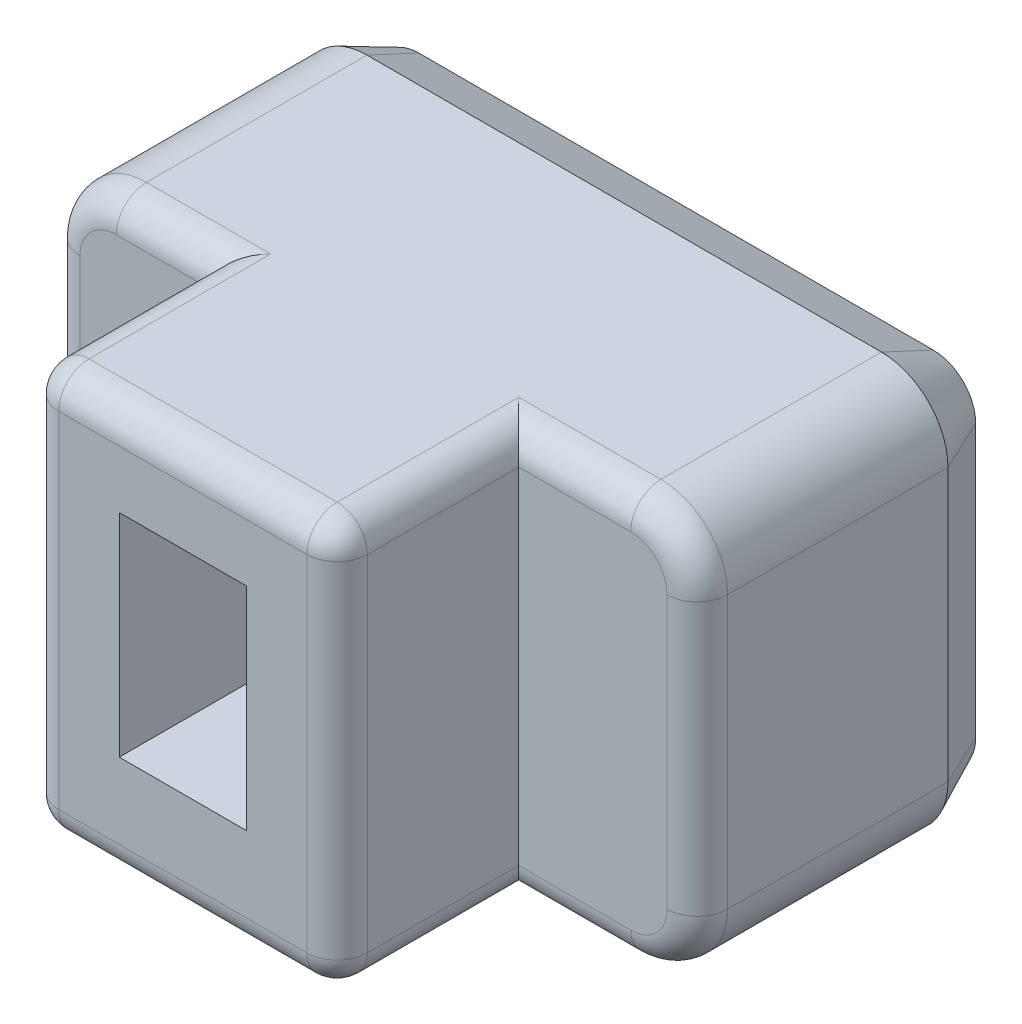
from build123d import *

# Parameters (mm, degrees)
BOSS_EXTRU_1_DEPTH      = 8
ESQUISSE3_W             = 2.1
ESQUISSE3_H             = 3.5
ENL_V_MAT_EXTRU_1_DEPTH = 3
ESQUISSE4_OUTSIDE_W     = 15.69
ESQUISSE4_OUTSIDE_H     = 11.69
ESQUISSE4_OUTSIDE_W_2   = 5.1
ESQUISSE4_OUTSIDE_H_2   = 6.7
ENL_V_MAT_EXTRU_2_DEPTH = 3
CONG_1_R                = 0.5
CHANFREIN1_SIZE         = 0.4
CHANFREIN1_SIZE2        = 0.857802768
ESQUISSE5_W             = 1.025354295
ESQUISSE5_H             = 0.378985829
ENL_V_MAT_EXTRU_3_DEPTH = 0.2
BOSS_EXTRU_2_DEPTH      = 0.2
ESQUISSE5_4_W           = 1.025354295
ESQUISSE5_4_H           = 0.378985829
BOSS_EXTRU_2_2_DEPTH    = 0.2
BOSS_EXTRU_2_3_DEPTH    = 0.2


with BuildPart() as part:
    # Esquisse2 → Boss.-Extru.1 (new body)
    with BuildSketch(Plane.XY):
        with BuildLine():
            Line((1.1, 0), (9.6, 0))
            ThreePointArc((9.6, 0), (10.377817459, 0.322182541), (10.7, 1.1))
            Line((10.7, 1.1), (10.7, 5.6))
            ThreePointArc((10.7, 5.6), (10.377817459, 6.377817459), (9.6, 6.7))
            Line((9.6, 6.7), (1.1, 6.7))
            ThreePointArc((1.1, 6.7), (0.322182541, 6.377817459), (0, 5.6))
            Line((0, 5.6), (0, 1.1))
            ThreePointArc((0, 1.1), (0.322182541, 0.322182541), (1.1, 0))
        make_face()
    extrude(amount=BOSS_EXTRU_1_DEPTH)

    # Esquisse3 → Enlèv. mat.-Extru.1 (cut)
    with BuildSketch(Plane.XY.offset(8)):
        with Locations((5.2, 3.5)):
            Rectangle(ESQUISSE3_W, ESQUISSE3_H)
    extrude(amount=-ENL_V_MAT_EXTRU_1_DEPTH, mode=Mode.SUBTRACT)

    # Esquisse4 outside → Enlèv. mat.-Extru.2 (cut)
    with BuildSketch(Plane.XY.offset(8)):
        with Locations((5.35, 3.35)):
            Rectangle(ESQUISSE4_OUTSIDE_W, ESQUISSE4_OUTSIDE_H)
        with Locations((5.2, 3.35)):
            Rectangle(ESQUISSE4_OUTSIDE_W_2, ESQUISSE4_OUTSIDE_H_2, mode=Mode.SUBTRACT)
    extrude(amount=-ENL_V_MAT_EXTRU_2_DEPTH, mode=Mode.SUBTRACT)

    # Congé1
    cong_1_edges = [part.edges().sort_by_distance(p)[0] for p in [
        (8.675, 0, 5),
        (10.377817459, 0.322182541, 5),
        (10.7, 3.35, 5),
        (10.377817459, 6.377817459, 5),
        (1.875, 6.7, 5),
        (0.322182541, 6.377817459, 5),
        (1.875, 0, 5),
        (0.322182541, 0.322182541, 5),
        (7.75, 6.7, 6.5),
        (2.65, 6.7, 6.5),
        (7.75, 0, 6.5),
        (2.65, 0, 6.5),
        (2.65, 3.35, 8),
        (5.2, 6.7, 8),
        (7.75, 3.35, 8),
        (5.2, 0, 8),
        (8.675, 6.7, 5),
        (0, 3.35, 5),
    ]]
    fillet(cong_1_edges, radius=CONG_1_R)

    # Chanfrein1
    chanfrein1_edges = [part.edges().sort_by_distance(p)[0] for p in [
        (5.35, 0, 0),
        (10.377817459, 0.322182541, 0),
        (0.322182541, 0.322182541, 0),
        (10.7, 3.35, 0),
        (0, 3.35, 0),
        (10.377817459, 6.377817459, 0),
        (0.322182541, 6.377817459, 0),
        (5.35, 6.7, 0),
    ]]
    chanfrein1_side = [part.faces().sort_by_distance(p)[0] for p in [
        (5.35, 3.35, 0),
    ]]
    chamfer(chanfrein1_edges, length=CHANFREIN1_SIZE, length2=CHANFREIN1_SIZE2, reference=chanfrein1_side[0])

    # Esquisse5 → Enlèv. mat.-Extru.3 (cut)
    # profile 1 of 3: a face of its own
    with BuildSketch(Plane.XY):
        with BuildLine():
            add(Edge.make_bspline(
                [(4.929449844, 3.327498458), (4.928886171, 3.377910145), (4.927777021, 3.477106133), (4.913601196, 3.623501248), (4.893366306, 3.765198874), (4.863662836, 3.902141775), (4.826132718, 4.033610013), (4.779556169, 4.158797974), (4.724522324, 4.277096054), (4.660463786, 4.388376577), (4.588776461, 4.493574952), (4.506874555, 4.590024638), (4.418032325, 4.680339759), (4.320049141, 4.762328436), (4.213891625, 4.837218253), (4.098307941, 4.90208427), (3.974955321, 4.959484949), (3.887876016, 4.988919822), (3.843643821, 5.003871354)],
                knots=[0, 0, 0, 0, 1.123878421, 2.21147591, 3.277260197, 4.314665604, 5.334010396, 6.323947346, 7.290538082, 8.24029135, 9.184804826, 10.125373713, 11.058341454, 12.007028084, 12.970867444, 13.951353182, 14.959383669, 16, 16, 16, 16], degree=3))
            add(Edge.make_bspline(
                [(3.843643821, 5.003871354), (3.789912082, 5.019016461), (3.679254836, 5.050206887), (3.502499471, 5.075001227), (3.312810463, 5.091003658), (3.181557586, 5.092318076), (3.113572962, 5.092998901)],
                knots=[0, 0, 0, 0, 0.90656597, 1.867017452, 2.895185995, 4, 4, 4, 4], degree=3))
            Line((3.113572962, 5.092998901), (2.409077833, 5.092998901))
            Line((2.409077833, 5.092998901), (2.409077833, 1.592998901))
            Line((2.409077833, 1.592998901), (3.120548161, 1.592998901))
            add(Edge.make_bspline(
                [(3.120548161, 1.592998901), (3.188520627, 1.593804974), (3.319729447, 1.595360956), (3.50960112, 1.609682498), (3.686149149, 1.636076993), (3.796873472, 1.667078383), (3.85061902, 1.682126447)],
                knots=[0, 0, 0, 0, 1.104726419, 2.132478913, 3.093505899, 4, 4, 4, 4], degree=3))
            add(Edge.make_bspline(
                [(3.85061902, 1.682126447), (3.894821605, 1.697142904), (3.981741078, 1.726671098), (4.105308916, 1.783032384), (4.220562381, 1.847357764), (4.326977684, 1.920222615), (4.42442678, 2.001555403), (4.513450744, 2.089645794), (4.59386311, 2.184840849), (4.665312975, 2.28683289), (4.72859397, 2.395515198), (4.781344797, 2.511870914), (4.82858433, 2.633347502), (4.865450647, 2.761858032), (4.893756086, 2.895844348), (4.914835009, 3.035029601), (4.927468569, 3.179490952), (4.928782066, 3.277613308), (4.929449844, 3.327498458)],
                knots=[0, 0, 0, 0, 1.055129885, 2.074795748, 3.0660858, 4.03671011, 4.986650223, 5.932630135, 6.865385513, 7.800552627, 8.745449603, 9.70470299, 10.686583926, 11.690463595, 12.723975734, 13.781512585, 14.872126769, 16, 16, 16, 16], degree=3))
        make_face()
        with BuildLine():
            add(Edge.make_bspline(
                [(4.529538418, 3.327498458), (4.528992862, 3.286400298), (4.527924312, 3.205903549), (4.518147111, 3.088501479), (4.504173153, 2.976755021), (4.481803596, 2.871363866), (4.455715845, 2.771170033), (4.420735035, 2.677813392), (4.381781679, 2.589786146), (4.335464015, 2.508236118), (4.284615762, 2.431743733), (4.226977419, 2.362134044), (4.164317439, 2.298073685), (4.097117361, 2.238916215), (4.024003907, 2.186300791), (3.945729841, 2.139362346), (3.862159311, 2.098319816), (3.803525417, 2.075663084), (3.773891828, 2.064212364)],
                knots=[0, 0, 0, 0, 1.246753459, 2.441948741, 3.572739138, 4.66116684, 5.708921826, 6.71080927, 7.682622944, 8.626727097, 9.552892984, 10.466231949, 11.364237833, 12.269773083, 13.17920167, 14.093347591, 15.036377251, 16, 16, 16, 16], degree=3))
            add(Edge.make_bspline(
                [(3.773891828, 2.064212364), (3.724847084, 2.049050908), (3.622993128, 2.017564266), (3.487675217, 1.99731781), (3.371721375, 1.988032345), (3.277452151, 1.981191627), (3.177653465, 1.978718026), (3.109181032, 1.97785349), (3.074046833, 1.977409884)],
                knots=[0, 0, 0, 0, 1.303000307, 2.706013413, 3.463799367, 4.259858732, 5.107108259, 6, 6, 6, 6], degree=3))
            Line((3.074046833, 1.977409884), (2.788063662, 1.977409884))
            Line((2.788063662, 1.977409884), (2.788063662, 4.708587918))
            Line((2.788063662, 4.708587918), (3.074046833, 4.708587918))
            add(Edge.make_bspline(
                [(3.074046833, 4.708587918), (3.109187702, 4.708605057), (3.177684847, 4.708638464), (3.277389955, 4.704111547), (3.371810318, 4.699378216), (3.487522058, 4.687803984), (3.623219634, 4.669854997), (3.72488446, 4.637420457), (3.773891828, 4.621785438)],
                knots=[0, 0, 0, 0, 0.892652841, 1.739973182, 2.535478049, 3.293719468, 4.695441758, 6, 6, 6, 6], degree=3))
            add(Edge.make_bspline(
                [(3.773891828, 4.621785438), (3.803541153, 4.61037347), (3.862313241, 4.587752207), (3.94599411, 4.545963014), (4.023785024, 4.497226527), (4.097351616, 4.443975775), (4.164848643, 4.383183707), (4.226696609, 4.316028425), (4.284926846, 4.24405854), (4.335439254, 4.164490225), (4.381795522, 4.079879262), (4.420758199, 3.988771473), (4.45542782, 3.892746892), (4.481946017, 3.790375103), (4.504148468, 3.682869359), (4.51805281, 3.569325495), (4.527958703, 3.450385665), (4.529003454, 3.369113736), (4.529538418, 3.327498458)],
                knots=[0, 0, 0, 0, 0.947957508, 1.879079663, 2.786395923, 3.685581737, 4.586617323, 5.49235929, 6.408837464, 7.345689656, 8.301456099, 9.285667611, 10.300283175, 11.345897504, 12.439299688, 13.574643735, 14.758096734, 16, 16, 16, 16], degree=3))
        make_face(mode=Mode.SUBTRACT)
    # profile 2 of 3: a face of its own
    with BuildSketch(Plane.XY):
        with Locations((5.751825841, 3.789024144)):
            Rectangle(ESQUISSE5_W, ESQUISSE5_H)
    # profile 3 of 3: a face of its own
    with BuildSketch(Plane.XY):
        Polygon((8.076194751, 3.709584375), (8.076194751, 3.698734065), (6.537000774, 2.851634862), (6.537000774, 2.458698635), (8.443555247, 3.525904127), (8.443555247, 3.881639291), (6.537000774, 4.948844782), (6.537000774, 4.556683578), align=None)
    extrude(amount=ENL_V_MAT_EXTRU_3_DEPTH, mode=Mode.SUBTRACT)


with BuildPart() as body_2:
    # Esquisse5_4 → Boss.-Extru.2 (new body)
    with BuildSketch(Plane.XY):
        with BuildLine():
            add(Edge.make_bspline(
                [(4.929449844, 3.327498458), (4.928886171, 3.377910145), (4.927777021, 3.477106133), (4.913601196, 3.623501248), (4.893366306, 3.765198874), (4.863662836, 3.902141775), (4.826132718, 4.033610013), (4.779556169, 4.158797974), (4.724522324, 4.277096054), (4.660463786, 4.388376577), (4.588776461, 4.493574952), (4.506874555, 4.590024638), (4.418032325, 4.680339759), (4.320049141, 4.762328436), (4.213891625, 4.837218253), (4.098307941, 4.90208427), (3.974955321, 4.959484949), (3.887876016, 4.988919822), (3.843643821, 5.003871354)],
                knots=[0, 0, 0, 0, 1.123878421, 2.21147591, 3.277260197, 4.314665604, 5.334010396, 6.323947346, 7.290538082, 8.24029135, 9.184804826, 10.125373713, 11.058341454, 12.007028084, 12.970867444, 13.951353182, 14.959383669, 16, 16, 16, 16], degree=3))
            add(Edge.make_bspline(
                [(3.843643821, 5.003871354), (3.789912082, 5.019016461), (3.679254836, 5.050206887), (3.502499471, 5.075001227), (3.312810463, 5.091003658), (3.181557586, 5.092318076), (3.113572962, 5.092998901)],
                knots=[0, 0, 0, 0, 0.90656597, 1.867017452, 2.895185995, 4, 4, 4, 4], degree=3))
            Line((3.113572962, 5.092998901), (2.409077833, 5.092998901))
            Line((2.409077833, 5.092998901), (2.409077833, 1.592998901))
            Line((2.409077833, 1.592998901), (3.120548161, 1.592998901))
            add(Edge.make_bspline(
                [(3.120548161, 1.592998901), (3.188520627, 1.593804974), (3.319729447, 1.595360956), (3.50960112, 1.609682498), (3.686149149, 1.636076993), (3.796873472, 1.667078383), (3.85061902, 1.682126447)],
                knots=[0, 0, 0, 0, 1.104726419, 2.132478913, 3.093505899, 4, 4, 4, 4], degree=3))
            add(Edge.make_bspline(
                [(3.85061902, 1.682126447), (3.894821605, 1.697142904), (3.981741078, 1.726671098), (4.105308916, 1.783032384), (4.220562381, 1.847357764), (4.326977684, 1.920222615), (4.42442678, 2.001555403), (4.513450744, 2.089645794), (4.59386311, 2.184840849), (4.665312975, 2.28683289), (4.72859397, 2.395515198), (4.781344797, 2.511870914), (4.82858433, 2.633347502), (4.865450647, 2.761858032), (4.893756086, 2.895844348), (4.914835009, 3.035029601), (4.927468569, 3.179490952), (4.928782066, 3.277613308), (4.929449844, 3.327498458)],
                knots=[0, 0, 0, 0, 1.055129885, 2.074795748, 3.0660858, 4.03671011, 4.986650223, 5.932630135, 6.865385513, 7.800552627, 8.745449603, 9.70470299, 10.686583926, 11.690463595, 12.723975734, 13.781512585, 14.872126769, 16, 16, 16, 16], degree=3))
        make_face()
        with BuildLine():
            add(Edge.make_bspline(
                [(4.529538418, 3.327498458), (4.528992862, 3.286400298), (4.527924312, 3.205903549), (4.518147111, 3.088501479), (4.504173153, 2.976755021), (4.481803596, 2.871363866), (4.455715845, 2.771170033), (4.420735035, 2.677813392), (4.381781679, 2.589786146), (4.335464015, 2.508236118), (4.284615762, 2.431743733), (4.226977419, 2.362134044), (4.164317439, 2.298073685), (4.097117361, 2.238916215), (4.024003907, 2.186300791), (3.945729841, 2.139362346), (3.862159311, 2.098319816), (3.803525417, 2.075663084), (3.773891828, 2.064212364)],
                knots=[0, 0, 0, 0, 1.246753459, 2.441948741, 3.572739138, 4.66116684, 5.708921826, 6.71080927, 7.682622944, 8.626727097, 9.552892984, 10.466231949, 11.364237833, 12.269773083, 13.17920167, 14.093347591, 15.036377251, 16, 16, 16, 16], degree=3))
            add(Edge.make_bspline(
                [(3.773891828, 2.064212364), (3.724847084, 2.049050908), (3.622993128, 2.017564266), (3.487675217, 1.99731781), (3.371721375, 1.988032345), (3.277452151, 1.981191627), (3.177653465, 1.978718026), (3.109181032, 1.97785349), (3.074046833, 1.977409884)],
                knots=[0, 0, 0, 0, 1.303000307, 2.706013413, 3.463799367, 4.259858732, 5.107108259, 6, 6, 6, 6], degree=3))
            Line((3.074046833, 1.977409884), (2.788063662, 1.977409884))
            Line((2.788063662, 1.977409884), (2.788063662, 4.708587918))
            Line((2.788063662, 4.708587918), (3.074046833, 4.708587918))
            add(Edge.make_bspline(
                [(3.074046833, 4.708587918), (3.109187702, 4.708605057), (3.177684847, 4.708638464), (3.277389955, 4.704111547), (3.371810318, 4.699378216), (3.487522058, 4.687803984), (3.623219634, 4.669854997), (3.72488446, 4.637420457), (3.773891828, 4.621785438)],
                knots=[0, 0, 0, 0, 0.892652841, 1.739973182, 2.535478049, 3.293719468, 4.695441758, 6, 6, 6, 6], degree=3))
            add(Edge.make_bspline(
                [(3.773891828, 4.621785438), (3.803541153, 4.61037347), (3.862313241, 4.587752207), (3.94599411, 4.545963014), (4.023785024, 4.497226527), (4.097351616, 4.443975775), (4.164848643, 4.383183707), (4.226696609, 4.316028425), (4.284926846, 4.24405854), (4.335439254, 4.164490225), (4.381795522, 4.079879262), (4.420758199, 3.988771473), (4.45542782, 3.892746892), (4.481946017, 3.790375103), (4.504148468, 3.682869359), (4.51805281, 3.569325495), (4.527958703, 3.450385665), (4.529003454, 3.369113736), (4.529538418, 3.327498458)],
                knots=[0, 0, 0, 0, 0.947957508, 1.879079663, 2.786395923, 3.685581737, 4.586617323, 5.49235929, 6.408837464, 7.345689656, 8.301456099, 9.285667611, 10.300283175, 11.345897504, 12.439299688, 13.574643735, 14.758096734, 16, 16, 16, 16], degree=3))
        make_face(mode=Mode.SUBTRACT)
    extrude(amount=-BOSS_EXTRU_2_DEPTH)


with BuildPart() as body_3:
    # Esquisse5_4 → Boss.-Extru.2 2 (new body)
    with BuildSketch(Plane.XY):
        with Locations((5.751825841, 3.789024144)):
            Rectangle(ESQUISSE5_4_W, ESQUISSE5_4_H)
    extrude(amount=-BOSS_EXTRU_2_2_DEPTH)


with BuildPart() as body_4:
    # Esquisse5_4 → Boss.-Extru.2 3 (new body)
    with BuildSketch(Plane.XY):
        Polygon((8.076194751, 3.709584375), (8.076194751, 3.698734065), (6.537000774, 2.851634862), (6.537000774, 2.458698635), (8.443555247, 3.525904127), (8.443555247, 3.881639291), (6.537000774, 4.948844782), (6.537000774, 4.556683578), align=None)
    extrude(amount=-BOSS_EXTRU_2_3_DEPTH)


solid = Compound([part.part, body_2.part, body_3.part, body_4.part])
